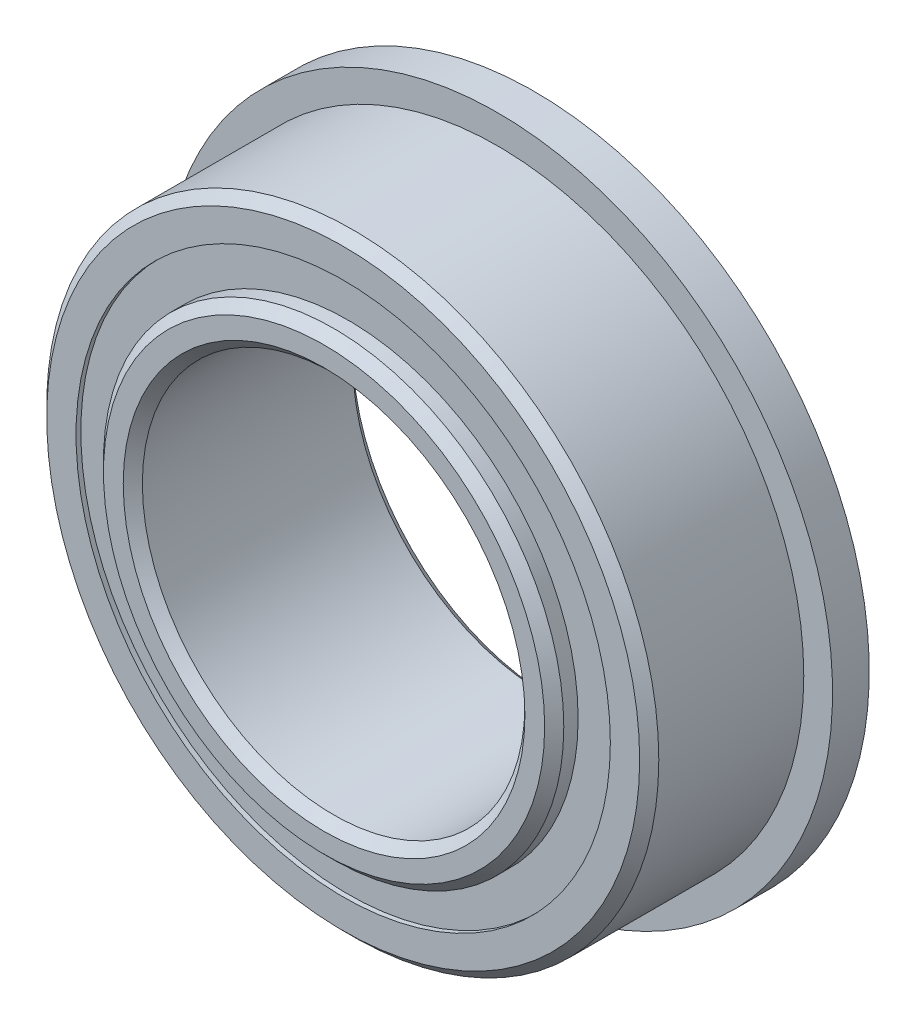
from build123d import *

# Parameters (mm, degrees)
CIRPATTERN1_COUNT = 12
SKETCH5_W         = 0.923323783
SKETCH5_H         = 0.767582418
SKETCH6_W         = 0.762
SKETCH6_H         = 1.403733791


with BuildPart() as part:
    # Sketch1 → Revolve1 (revolve)
    with BuildSketch(Plane(origin=(0, 0, 0), x_dir=(0, 0, -1), z_dir=(1, 0, 0))):
        with BuildLine():
            Line((1.7859375, 6.35), (-1.7859375, 6.35))
            Line((-1.7859375, 6.35), (-1.984375, 6.1515625))
            Line((-1.984375, 6.1515625), (-1.984375, 5.543166209))
            Line((-1.984375, 5.543166209), (-0.881944444, 5.543166209))
            ThreePointArc((-0.881944444, 5.543166209), (0, 6.121207467), (0.881944444, 5.543166209))
            Line((0.881944444, 5.543166209), (1.984375, 5.543166209))
            Line((1.984375, 5.543166209), (1.984375, 6.1515625))
            Line((1.984375, 6.1515625), (1.7859375, 6.35))
        make_face()
    revolve(axis=Axis((0, 0, 1.984375), (0, 0, -1)))

    # Sketch6 → Revolve6 (revolve)
    with BuildSketch(Plane(origin=(0, 0, 0), x_dir=(0, 0, -1), z_dir=(1, 0, 0))):
        with Locations((1.603375, 6.245033105)):
            Rectangle(SKETCH6_W, SKETCH6_H)
    revolve(axis=Axis((0, 0, -1.984375), (0, 0, 1)))


with BuildPart() as body_2:
    # Sketch3 → Revolve3 (revolve)
    with BuildSketch(Plane(origin=(0, 0, 0), x_dir=(0, 0, -1), z_dir=(1, 0, 0))):
        with BuildLine():
            Line((-2.38125, 4.1671875), (-2.38125, 4.577146291))
            Line((-2.38125, 4.577146291), (-2.1828125, 4.775583791))
            Line((-2.1828125, 4.775583791), (-0.881944444, 4.775583791))
            ThreePointArc((-0.881944444, 4.775583791), (0, 4.197542533), (0.881944444, 4.775583791))
            Line((0.881944444, 4.775583791), (2.1828125, 4.775583791))
            Line((2.1828125, 4.775583791), (2.38125, 4.577146291))
            Line((2.38125, 4.577146291), (2.38125, 4.1671875))
            Line((2.38125, 4.1671875), (2.1828125, 3.96875))
            Line((2.1828125, 3.96875), (-2.1828125, 3.96875))
            Line((-2.1828125, 3.96875), (-2.38125, 4.1671875))
        make_face()
    revolve(axis=Axis((0, 0, 1.984375), (0, 0, -1)))


with BuildPart() as body_3:
    # Sketch4 → Revolve4 (revolve)
    with BuildSketch(Plane(origin=(0, 0, 0), x_dir=(0, 0, -1), z_dir=(1, 0, 0))):
        with BuildLine():
            Line((-0.961832467, 5.159375), (0.961832467, 5.159375))
            ThreePointArc((0.961832467, 5.159375), (0, 6.121207467), (-0.961832467, 5.159375))
        make_face()
    revolve(axis=Axis((0, 5.159375, 0.961832467), (0, 0, -1)))


with BuildPart() as cirpattern1_1:
    # CirPattern1: pattern copy
    add(body_3.part.rotate(Axis((0, 0, -1.984375), (0, 0, 1)), 1 * 360 / CIRPATTERN1_COUNT))


with BuildPart() as cirpattern1_2:
    # CirPattern1: pattern copy
    add(body_3.part.rotate(Axis((0, 0, -1.984375), (0, 0, 1)), 2 * 360 / CIRPATTERN1_COUNT))


with BuildPart() as cirpattern1_3:
    # CirPattern1: pattern copy
    add(body_3.part.rotate(Axis((0, 0, -1.984375), (0, 0, 1)), 3 * 360 / CIRPATTERN1_COUNT))


with BuildPart() as cirpattern1_4:
    # CirPattern1: pattern copy
    add(body_3.part.rotate(Axis((0, 0, -1.984375), (0, 0, 1)), 4 * 360 / CIRPATTERN1_COUNT))


with BuildPart() as cirpattern1_5:
    # CirPattern1: pattern copy
    add(body_3.part.rotate(Axis((0, 0, -1.984375), (0, 0, 1)), 5 * 360 / CIRPATTERN1_COUNT))


with BuildPart() as cirpattern1_6:
    # CirPattern1: pattern copy
    add(body_3.part.rotate(Axis((0, 0, -1.984375), (0, 0, 1)), 6 * 360 / CIRPATTERN1_COUNT))


with BuildPart() as cirpattern1_7:
    # CirPattern1: pattern copy
    add(body_3.part.rotate(Axis((0, 0, -1.984375), (0, 0, 1)), 7 * 360 / CIRPATTERN1_COUNT))


with BuildPart() as cirpattern1_8:
    # CirPattern1: pattern copy
    add(body_3.part.rotate(Axis((0, 0, -1.984375), (0, 0, 1)), 8 * 360 / CIRPATTERN1_COUNT))


with BuildPart() as cirpattern1_9:
    # CirPattern1: pattern copy
    add(body_3.part.rotate(Axis((0, 0, -1.984375), (0, 0, 1)), 9 * 360 / CIRPATTERN1_COUNT))


with BuildPart() as cirpattern1_10:
    # CirPattern1: pattern copy
    add(body_3.part.rotate(Axis((0, 0, -1.984375), (0, 0, 1)), 10 * 360 / CIRPATTERN1_COUNT))


with BuildPart() as cirpattern1_11:
    # CirPattern1: pattern copy
    add(body_3.part.rotate(Axis((0, 0, -1.984375), (0, 0, 1)), 11 * 360 / CIRPATTERN1_COUNT))


with BuildPart() as body_15:
    # Sketch5 → Revolve5 (revolve)
    with BuildSketch(Plane(origin=(0, 0, 0), x_dir=(0, 0, -1), z_dir=(1, 0, 0))):
        with Locations((-1.423494359, 5.159375)):
            Rectangle(SKETCH5_W, SKETCH5_H)
        with Locations((1.423494359, 5.159375)):
            Rectangle(SKETCH5_W, SKETCH5_H)
    revolve(axis=Axis((0, 0, 1.984375), (0, 0, -1)))


solid = Compound([part.part, body_2.part, body_3.part, cirpattern1_1.part, cirpattern1_2.part, cirpattern1_3.part, cirpattern1_4.part, cirpattern1_5.part, cirpattern1_6.part, cirpattern1_7.part, cirpattern1_8.part, cirpattern1_9.part, cirpattern1_10.part, cirpattern1_11.part, body_15.part])
